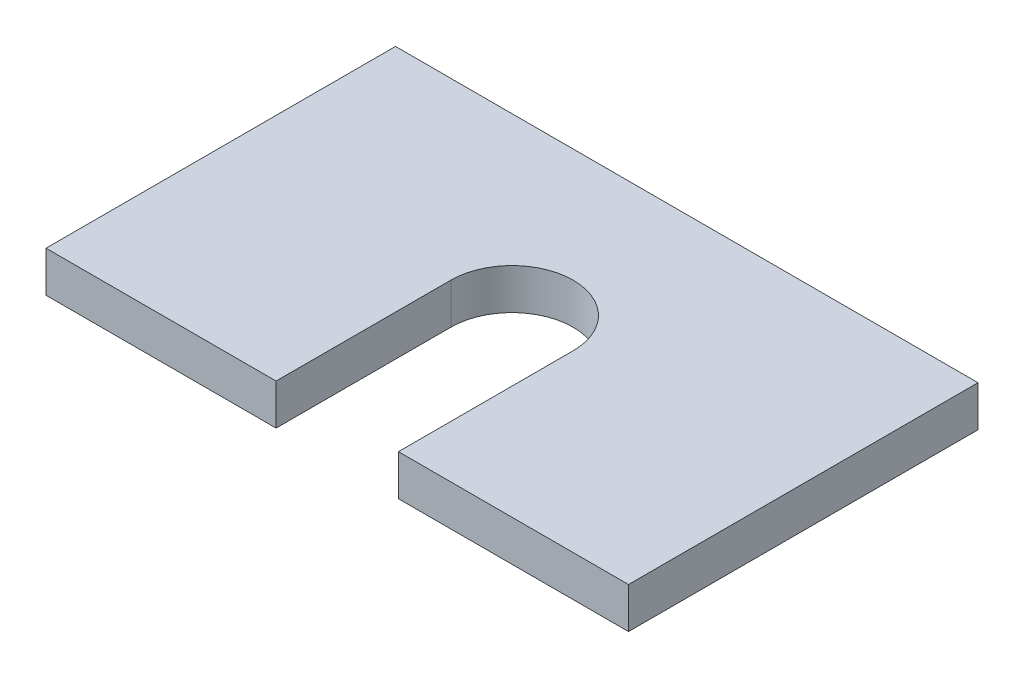
from build123d import *

# Parameters (mm, degrees)
BOSS_EXTRUDE1_DEPTH = 8.89


with BuildPart() as part:
    # Sketch1 → Boss-Extrude1 (new body)
    with BuildSketch(Plane(origin=(0, 0, 0), x_dir=(1, 0, 0), z_dir=(0, 1, 0))):
        with BuildLine():
            Line((-13.335, -38.1), (-13.335, 0))
            ThreePointArc((-13.335, 0), (0, 13.335), (13.335, 0))
            Line((13.335, 0), (13.335, -38.1))
            Line((13.335, -38.1), (63.5, -38.1))
            Line((63.5, -38.1), (63.5, 38.1))
            Line((63.5, 38.1), (-63.5, 38.1))
            Line((-63.5, 38.1), (-63.5, -38.1))
            Line((-63.5, -38.1), (-13.335, -38.1))
        make_face()
    extrude(amount=BOSS_EXTRUDE1_DEPTH)


solid = part.part
